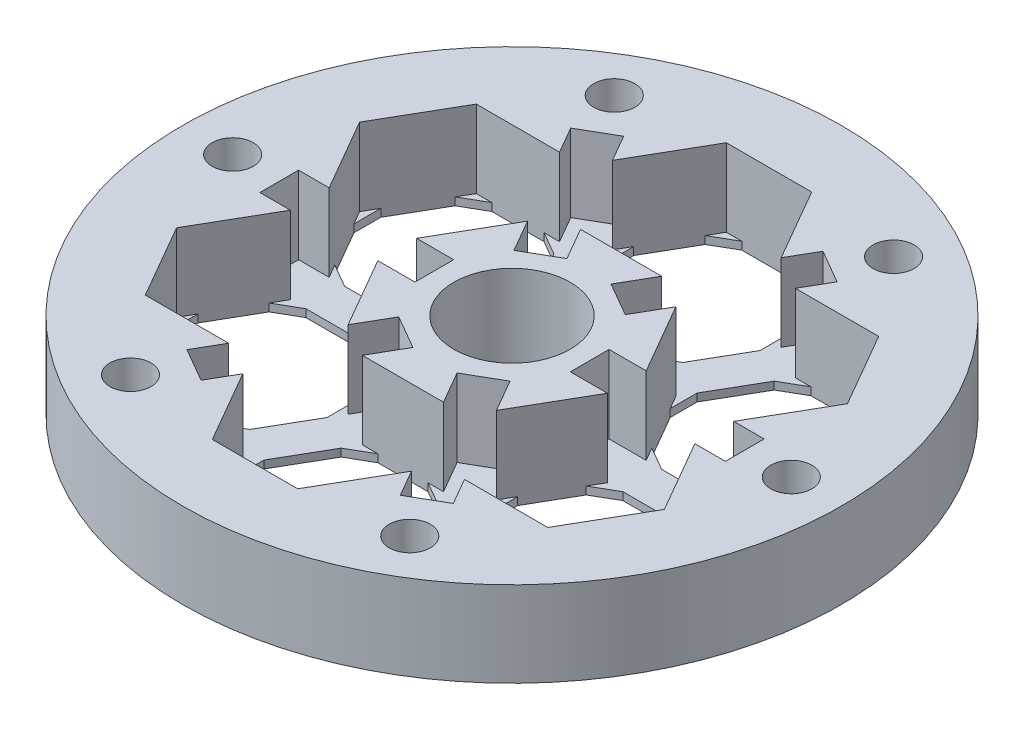
from build123d import *

# Parameters (mm, degrees)
SKETCH2_R               = 42.5
BOSS_EXTRUDE1_DEPTH     = 11
CUT_EXTRUDE3_DEPTH      = 11
SKETCH4_R               = 2.65
CUT_EXTRUDE4_DEPTH      = 12
SKETCH7_W               = 20
SKETCH7_H               = 5
BOSS_EXTRUDE2_DEPTH     = 1
SKETCH6_R               = 4.4
CUT_EXTRUDE6_DEPTH      = 5.4
SKETCH8_R               = 7.5
CUT_EXTRUDE7_DEPTH      = 1
CUT_EXTRUDE7_DEPTH_BACK = 12
BOSS_EXTRUDE3_DEPTH     = 1
CIRPATTERN1_COUNT       = 6


with BuildPart() as part:
    # Sketch2 → Boss-Extrude1 (new body)
    with BuildSketch(Plane(origin=(0, 0, 0), x_dir=(1, 0, 0), z_dir=(0, 1, 0))):
        Circle(SKETCH2_R)
    extrude(amount=BOSS_EXTRUDE1_DEPTH)

    # Sketch3 → Cut-Extrude3 (cut)
    with BuildSketch(Plane(origin=(0, 11, 0), x_dir=(1, 0, 0), z_dir=(0, 1, 0))):
        Polygon((10.876265015, 23.838243603), (5.505548638, 33.14059724), (-5.505548638, 33.14059724), (-10.876265015, 23.838243602), (-12.845675931, 27.249363369), (-17.175802949, 24.749363369), (-15.206392034, 21.338243603), (-25.947824787, 21.338243602), (-31.453373426, 11.802353637), (-26.082657049, 2.5), (-30.02147888, 2.5), (-30.02147888, -2.5), (-26.082657049, -2.5), (-31.453373426, -11.802353638), (-25.947824787, -21.338243603), (-15.206392034, -21.338243603), (-17.175802949, -24.749363369), (-12.845675931, -27.249363369), (-10.876265015, -23.838243603), (-5.505548638, -33.14059724), (5.505548638, -33.14059724), (10.876265015, -23.838243602), (12.845675931, -27.249363369), (17.175802949, -24.749363369), (15.206392034, -21.338243603), (25.947824787, -21.338243602), (31.453373426, -11.802353637), (26.082657049, -2.5), (30.02147888, -2.5), (30.02147888, 2.5), (26.082657049, 2.5), (31.453373426, 11.802353637), (25.947824787, 21.338243602), (15.206392034, 21.338243602), (17.175802949, 24.749363369), (12.845675931, 27.249363369), align=None)
        Polygon((-5.235884115, 14.06881731), (5.235884115, 14.06881731), (2.845675931, 9.928855294), (7.175802949, 7.428855294), (9.566011134, 11.56881731), (14.801895249, 2.5), (10.02147888, 2.5), (10.02147888, -2.5), (14.801895249, -2.5), (9.566011134, -11.56881731), (7.175802949, -7.428855294), (2.845675931, -9.928855294), (5.235884115, -14.06881731), (-5.235884115, -14.06881731), (-2.845675931, -9.928855294), (-7.175802949, -7.428855294), (-9.566011134, -11.56881731), (-14.801895249, -2.5), (-10.02147888, -2.5), (-10.02147888, 2.5), (-14.801895249, 2.5), (-9.566011134, 11.56881731), (-7.175802949, 7.428855294), (-2.845675931, 9.928855294), align=None, mode=Mode.SUBTRACT)
    extrude(amount=-CUT_EXTRUDE3_DEPTH, mode=Mode.SUBTRACT)

    # Sketch4 → Cut-Extrude4 (cut, through all)
    with BuildSketch(Plane(origin=(0, 11, 0), x_dir=(1, 0, 0), z_dir=(0, 1, 0))):
        with Locations((18.01073944, 31.195515792)):
            Circle(SKETCH4_R)
        with Locations((36.02147888, 0)):
            Circle(SKETCH4_R)
        with Locations((18.01073944, -31.195515792)):
            Circle(SKETCH4_R)
        with Locations((-18.01073944, -31.195515792)):
            Circle(SKETCH4_R)
        with Locations((-36.02147888, 0)):
            Circle(SKETCH4_R)
        with Locations((-18.01073944, 31.195515792)):
            Circle(SKETCH4_R)
    extrude(amount=-CUT_EXTRUDE4_DEPTH, mode=Mode.SUBTRACT)

    # Sketch7 → Boss-Extrude2 (add)
    with BuildSketch(Plane.XZ):
        Polygon((-7.175802949, 7.428855294), (-2.845675931, 9.928855294), (-12.845675931, 27.249363369), (-17.175802949, 24.749363369), align=None)
        Polygon((12.845675931, 27.249363369), (2.845675931, 9.928855294), (7.175802949, 7.428855294), (17.175802949, 24.749363369), align=None)
        with Locations((20.02147888, 0)):
            Rectangle(SKETCH7_W, SKETCH7_H)
        Polygon((17.175802949, -24.749363369), (7.175802949, -7.428855294), (2.845675931, -9.928855294), (12.845675931, -27.249363369), align=None)
        Polygon((-12.845675931, -27.249363369), (-2.845675931, -9.928855294), (-7.175802949, -7.428855294), (-17.175802949, -24.749363369), align=None)
        with Locations((-20.02147888, 0)):
            Rectangle(SKETCH7_W, SKETCH7_H)
    extrude(amount=-BOSS_EXTRUDE2_DEPTH)

    # Sketch6 → Cut-Extrude6 (cut)
    with BuildSketch(Plane(origin=(0, 0, 0), x_dir=(1, 0, 0), z_dir=(0, 1, 0))):
        with Locations((18.01073944, 31.195515792)):
            Circle(SKETCH6_R)
        with Locations((36.02147888, 0)):
            Circle(SKETCH6_R)
        with Locations((18.01073944, -31.195515792)):
            Circle(SKETCH6_R)
        with Locations((-18.01073944, -31.195515792)):
            Circle(SKETCH6_R)
        with Locations((-36.02147888, 0)):
            Circle(SKETCH6_R)
        with Locations((-18.01073944, 31.195515792)):
            Circle(SKETCH6_R)
    extrude(amount=CUT_EXTRUDE6_DEPTH, mode=Mode.SUBTRACT)

    # Sketch8 → Cut-Extrude7 (cut, two sides)
    with BuildSketch(Plane(origin=(0, 11, 0), x_dir=(1, 0, 0), z_dir=(0, 1, 0))) as cut_extrude7_sk:
        Circle(SKETCH8_R)
    extrude(amount=CUT_EXTRUDE7_DEPTH, mode=Mode.SUBTRACT)
    extrude(cut_extrude7_sk.sketch, amount=-CUT_EXTRUDE7_DEPTH_BACK, mode=Mode.SUBTRACT)

    # Sketch11 → Boss-Extrude3 (add)
    with BuildSketch(Plane.XZ):
        Polygon((17.206392034, 21.338243603), (14.206392034, 19.606192795), (15.206392034, 21.338243603), align=None)
        Polygon((25.947824787, 21.338243602), (26.947824787, 19.606192795), (23.947824787, 21.338243603), align=None)
        Polygon((30.453373426, 10.07030283), (31.453373426, 11.802353637), (30.453373426, 13.534404445), align=None)
        Polygon((24.082657049, 2.5), (27.082657049, 4.232050808), (26.082657049, 2.5), align=None)
        Polygon((13.801895249, 4.232050808), (14.801895249, 2.5), (16.801895249, 2.5), align=None)
        Polygon((10.566011134, 9.836766502), (9.566011134, 11.56881731), (10.566011134, 13.300868118), align=None)
    boss_extrude3 = extrude(amount=-BOSS_EXTRUDE3_DEPTH)

    # CirPattern1: Boss-Extrude3 ×6 about axis
    cirpattern1_axis = Axis((0, 0, 0), (0, 1, 0))
    for i in range(1, CIRPATTERN1_COUNT):
        add(boss_extrude3.rotate(cirpattern1_axis, i * 360 / CIRPATTERN1_COUNT))


solid = part.part
